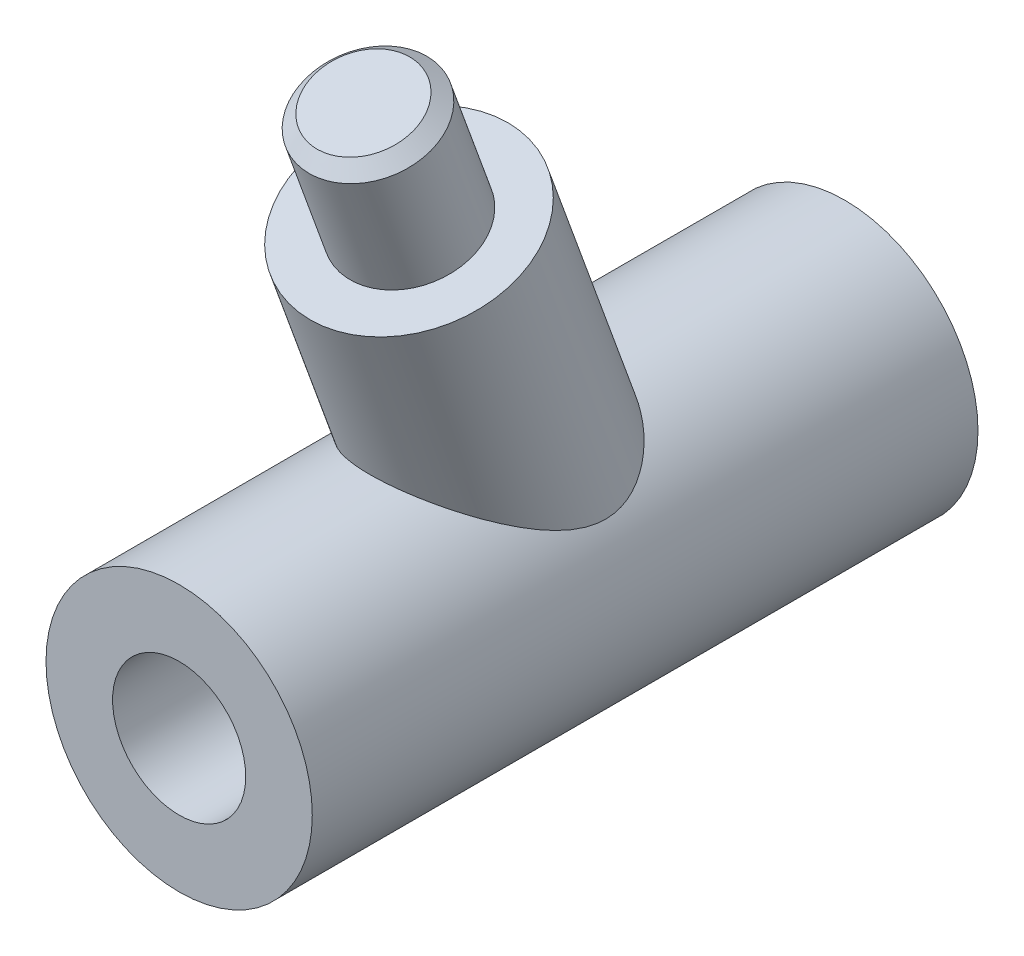
from build123d import *

# Parameters (mm, degrees)
SKETCH1_R           = 10
SKETCH1_R_2         = 5
BOSS_EXTRUDE1_DEPTH = 50
BOSS_EXTRUDE2_REACH = 46.087
SKETCH4_R           = 7.9
SKETCH6_R           = 4.7
BOSS_EXTRUDE3_DEPTH = 10
CHAMFER1_SIZE       = 1


with BuildPart() as part:
    # Sketch1 → Boss-Extrude1 (new body)
    with BuildSketch(Plane.XY):
        Circle(SKETCH1_R)
        Circle(SKETCH1_R_2, mode=Mode.SUBTRACT)
    extrude(amount=BOSS_EXTRUDE1_DEPTH)

    # Sketch4 → Boss-Extrude2 (add, up to next)
    with BuildSketch(Plane(origin=(0, 25, 32.738958199), x_dir=(-1, 0, 0), z_dir=(0, -0.939692621, -0.342020143)), mode=Mode.PRIVATE) as boss_extrude2_sk1:
        Circle(SKETCH4_R)
    boss_extrude2_tool1 = extrude(boss_extrude2_sk1.sketch, amount=BOSS_EXTRUDE2_REACH, mode=Mode.PRIVATE) - part.part
    add(boss_extrude2_tool1.solids().sort_by_distance((0, 25, 32.738958))[0])

    # Sketch6 → Boss-Extrude3 (add)
    with BuildSketch(Plane(origin=(0, 32.597653881, 11.86457572), x_dir=(1, 0, 0), z_dir=(0, 0.939692621, 0.342020143))):
        with Locations((0, -22.214053849)):
            Circle(SKETCH6_R)
    extrude(amount=BOSS_EXTRUDE3_DEPTH)

    # Chamfer1
    chamfer1_edges = [part.edges().sort_by_distance(p)[0] for p in [
        (-4.7, 34.396926208, 36.159159633),
    ]]
    chamfer(chamfer1_edges, length=CHAMFER1_SIZE)


solid = part.part
